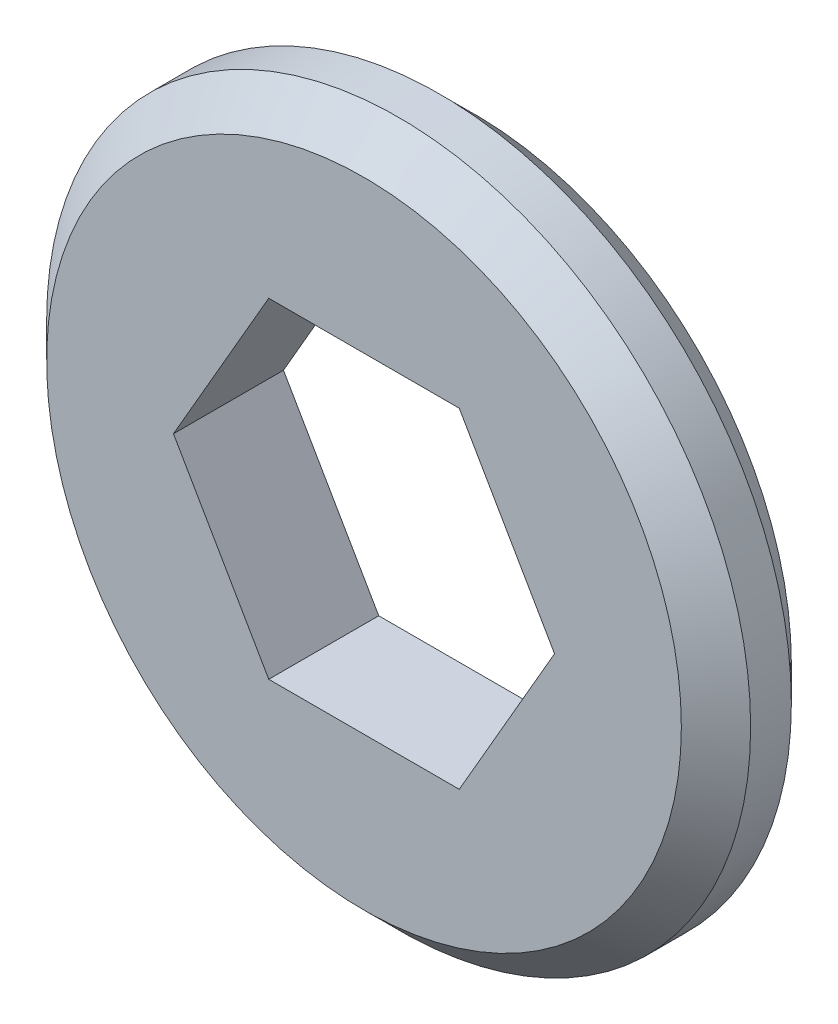
from build123d import *

# Parameters (mm, degrees)
SKETCH1_R           = 10.16
BOSS_EXTRUDE1_DEPTH = 3.175
CHAMFER1_SIZE       = 1


with BuildPart() as part:
    # Sketch1 → Boss-Extrude1 (new body)
    with BuildSketch(Plane.XY):
        Circle(SKETCH1_R)
        Polygon((5.499261314, 0), (2.749630657, 4.7625), (-2.749630657, 4.7625), (-5.499261314, 0), (-2.749630657, -4.7625), (2.749630657, -4.7625), align=None, mode=Mode.SUBTRACT)
    extrude(amount=BOSS_EXTRUDE1_DEPTH)

    # Chamfer1
    chamfer1_edges = [part.edges().sort_by_distance(p)[0] for p in [
        (-10.16, 0, 0),
        (-10.16, 0, 3.175),
    ]]
    chamfer(chamfer1_edges, length=CHAMFER1_SIZE)


solid = part.part
